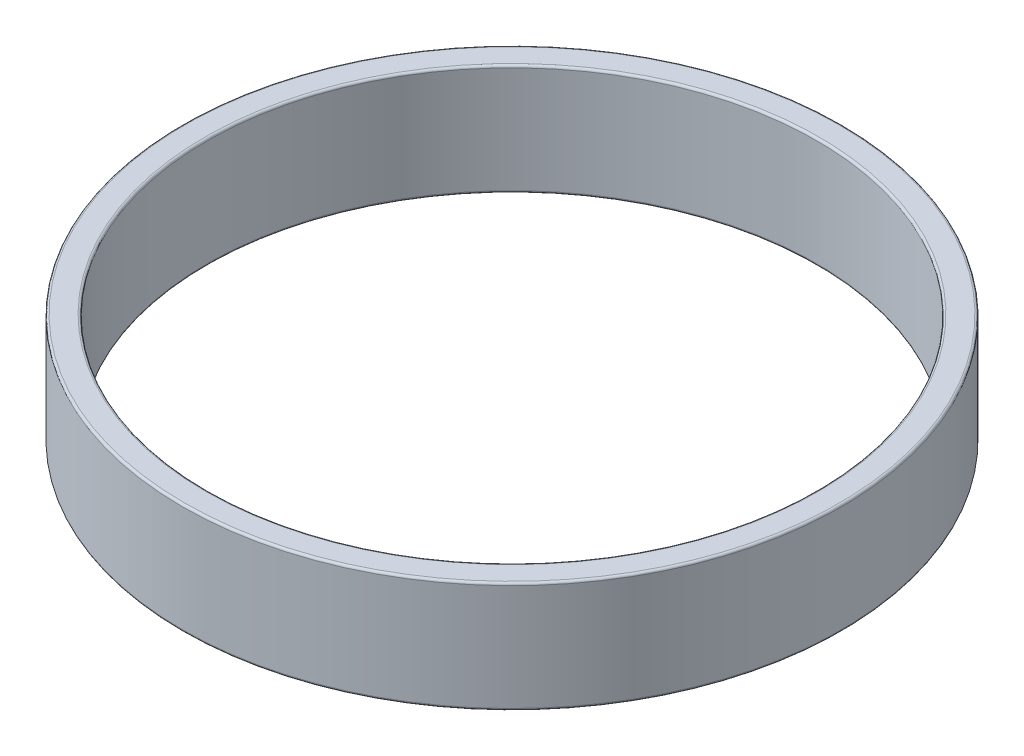
from build123d import *

# Parameters (mm, degrees)
SKETCH1_R           = 75.565
SKETCH1_R_2         = 69.85
BOSS_EXTRUDE1_DEPTH = 25.4
FILLET1_R           = 0.508


with BuildPart() as part:
    # Sketch1 → Boss-Extrude1 (new body)
    with BuildSketch(Plane(origin=(0, 0, 0), x_dir=(1, 0, 0), z_dir=(0, 1, 0))):
        Circle(SKETCH1_R)
        Circle(SKETCH1_R_2, mode=Mode.SUBTRACT)
    extrude(amount=BOSS_EXTRUDE1_DEPTH)

    # Fillet1
    fillet1_edges = [part.edges().sort_by_distance(p)[0] for p in [
        (-75.565, 0, 0),
        (-75.565, 25.4, 0),
        (-69.85, 0, 0),
        (-69.85, 25.4, 0),
    ]]
    fillet(fillet1_edges, radius=FILLET1_R)


solid = part.part
